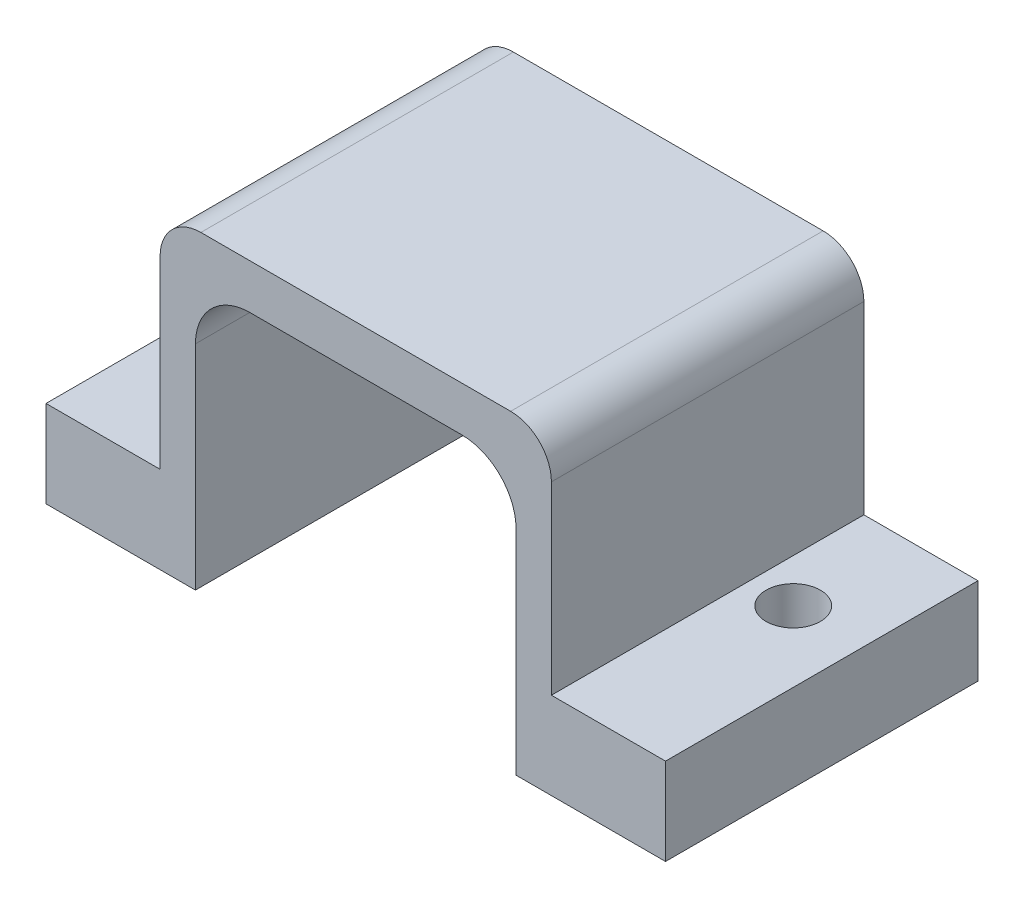
from build123d import *

# Parameters (mm, degrees)
EXTRUDE_1_DEPTH     = 11.5
FILLET_1_R          = 2
FILLET_2_R          = 1.5
SKETCH_2_R          = 1
CUT_EXTRUDE_1_DEPTH = 11.5


with BuildPart() as part:
    # 草图1 → 凸台-拉伸1 (new body)
    with BuildSketch(Plane.XY):
        Polygon((0, 0), (0, 9.85), (11.8, 9.85), (11.8, 0), (17.3, 0), (17.3, 3.2), (13.1, 3.2), (13.1, 11.5), (-1.3, 11.5), (-1.3, 3.2), (-5.5, 3.2), (-5.5, 0), align=None)
    extrude(amount=EXTRUDE_1_DEPTH)

    # 圆角1
    fillet_1_edges = [part.edges().sort_by_distance(p)[0] for p in [
        (11.8, 9.85, 5.75),
        (0, 9.85, 5.75),
    ]]
    fillet(fillet_1_edges, radius=FILLET_1_R)

    # 圆角2
    fillet_2_edges = [part.edges().sort_by_distance(p)[0] for p in [
        (-1.3, 11.5, 5.75),
        (13.1, 11.5, 5.75),
    ]]
    fillet(fillet_2_edges, radius=FILLET_2_R)

    # 草图2 → 切除-拉伸1 (cut)
    with BuildSketch(Plane(origin=(0, 3.2, 0), x_dir=(1, 0, 0), z_dir=(0, 1, 0))):
        with Locations((-2.9, -4.2)):
            Circle(SKETCH_2_R)
        with Locations((14.7, -4.2)):
            Circle(SKETCH_2_R)
    extrude(amount=-CUT_EXTRUDE_1_DEPTH, mode=Mode.SUBTRACT)


solid = part.part
